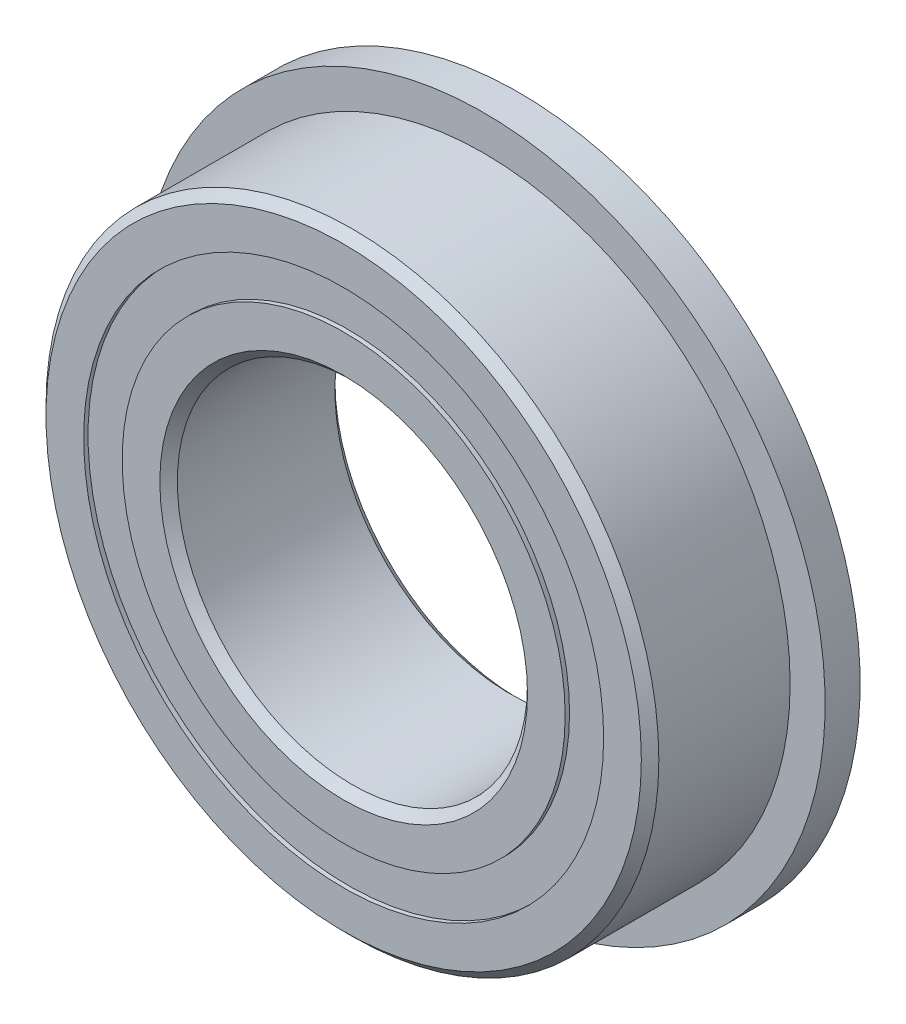
from build123d import *

# Parameters (mm, degrees)
CIRPATTERN1_COUNT = 12
SKETCH5_W         = 0.908366581
SKETCH5_H         = 0.87912088
SKETCH6_W         = 0.8
SKETCH6_H         = 1.86043956


with BuildPart() as part:
    # Sketch1 → Revolve1 (revolve)
    with BuildSketch(Plane(origin=(0, 0, 0), x_dir=(0, 0, -1), z_dir=(1, 0, 0))):
        with BuildLine():
            Line((1.8, 7), (-1.8, 7))
            Line((-1.8, 7), (-2, 6.8))
            Line((-2, 6.8), (-2, 5.93956044))
            Line((-2, 5.93956044), (-0.888888889, 5.93956044))
            ThreePointArc((-0.888888889, 5.93956044), (0, 6.491633419), (0.888888889, 5.93956044))
            Line((0.888888889, 5.93956044), (2, 5.93956044))
            Line((2, 5.93956044), (2, 6.8))
            Line((2, 6.8), (1.8, 7))
        make_face()
    revolve(axis=Axis((0, 0, 2), (0, 0, -1)))

    # Sketch6 → Revolve6 (revolve)
    with BuildSketch(Plane(origin=(0, 0, 0), x_dir=(0, 0, -1), z_dir=(1, 0, 0))):
        with Locations((1.6, 6.86978022)):
            Rectangle(SKETCH6_W, SKETCH6_H)
    revolve(axis=Axis((0, 0, -2), (0, 0, 1)))


with BuildPart() as body_2:
    # Sketch3 → Revolve3 (revolve)
    with BuildSketch(Plane(origin=(0, 0, 0), x_dir=(0, 0, -1), z_dir=(1, 0, 0))):
        with BuildLine():
            Line((-2, 5.06043956), (-0.888888889, 5.06043956))
            ThreePointArc((-0.888888889, 5.06043956), (0, 4.508366581), (0.888888889, 5.06043956))
            Line((0.888888889, 5.06043956), (2, 5.06043956))
            Line((2, 5.06043956), (2, 4.2))
            Line((2, 4.2), (1.8, 4))
            Line((1.8, 4), (-1.8, 4))
            Line((-1.8, 4), (-2, 4.2))
            Line((-2, 4.2), (-2, 5.06043956))
        make_face()
    revolve(axis=Axis((0, 0, 2), (0, 0, -1)))


with BuildPart() as body_3:
    # Sketch4 → Revolve4 (revolve)
    with BuildSketch(Plane(origin=(0, 0, 0), x_dir=(0, 0, -1), z_dir=(1, 0, 0))):
        with BuildLine():
            Line((-0.991633419, 5.5), (0.991633419, 5.5))
            ThreePointArc((0.991633419, 5.5), (0, 6.491633419), (-0.991633419, 5.5))
        make_face()
    revolve(axis=Axis((0, 5.5, 0.991633419), (0, 0, -1)))


with BuildPart() as cirpattern1_1:
    # CirPattern1: pattern copy
    add(body_3.part.rotate(Axis((0, 0, -2), (0, 0, 1)), 1 * 360 / CIRPATTERN1_COUNT))


with BuildPart() as cirpattern1_2:
    # CirPattern1: pattern copy
    add(body_3.part.rotate(Axis((0, 0, -2), (0, 0, 1)), 2 * 360 / CIRPATTERN1_COUNT))


with BuildPart() as cirpattern1_3:
    # CirPattern1: pattern copy
    add(body_3.part.rotate(Axis((0, 0, -2), (0, 0, 1)), 3 * 360 / CIRPATTERN1_COUNT))


with BuildPart() as cirpattern1_4:
    # CirPattern1: pattern copy
    add(body_3.part.rotate(Axis((0, 0, -2), (0, 0, 1)), 4 * 360 / CIRPATTERN1_COUNT))


with BuildPart() as cirpattern1_5:
    # CirPattern1: pattern copy
    add(body_3.part.rotate(Axis((0, 0, -2), (0, 0, 1)), 5 * 360 / CIRPATTERN1_COUNT))


with BuildPart() as cirpattern1_6:
    # CirPattern1: pattern copy
    add(body_3.part.rotate(Axis((0, 0, -2), (0, 0, 1)), 6 * 360 / CIRPATTERN1_COUNT))


with BuildPart() as cirpattern1_7:
    # CirPattern1: pattern copy
    add(body_3.part.rotate(Axis((0, 0, -2), (0, 0, 1)), 7 * 360 / CIRPATTERN1_COUNT))


with BuildPart() as cirpattern1_8:
    # CirPattern1: pattern copy
    add(body_3.part.rotate(Axis((0, 0, -2), (0, 0, 1)), 8 * 360 / CIRPATTERN1_COUNT))


with BuildPart() as cirpattern1_9:
    # CirPattern1: pattern copy
    add(body_3.part.rotate(Axis((0, 0, -2), (0, 0, 1)), 9 * 360 / CIRPATTERN1_COUNT))


with BuildPart() as cirpattern1_10:
    # CirPattern1: pattern copy
    add(body_3.part.rotate(Axis((0, 0, -2), (0, 0, 1)), 10 * 360 / CIRPATTERN1_COUNT))


with BuildPart() as cirpattern1_11:
    # CirPattern1: pattern copy
    add(body_3.part.rotate(Axis((0, 0, -2), (0, 0, 1)), 11 * 360 / CIRPATTERN1_COUNT))


with BuildPart() as body_15:
    # Sketch5 → Revolve5 (revolve)
    with BuildSketch(Plane(origin=(0, 0, 0), x_dir=(0, 0, -1), z_dir=(1, 0, 0))):
        with Locations((-1.44581671, 5.5)):
            Rectangle(SKETCH5_W, SKETCH5_H)
        with Locations((1.44581671, 5.5)):
            Rectangle(SKETCH5_W, SKETCH5_H)
    revolve(axis=Axis((0, 0, 2), (0, 0, -1)))


solid = Compound([part.part, body_2.part, body_3.part, cirpattern1_1.part, cirpattern1_2.part, cirpattern1_3.part, cirpattern1_4.part, cirpattern1_5.part, cirpattern1_6.part, cirpattern1_7.part, cirpattern1_8.part, cirpattern1_9.part, cirpattern1_10.part, cirpattern1_11.part, body_15.part])
